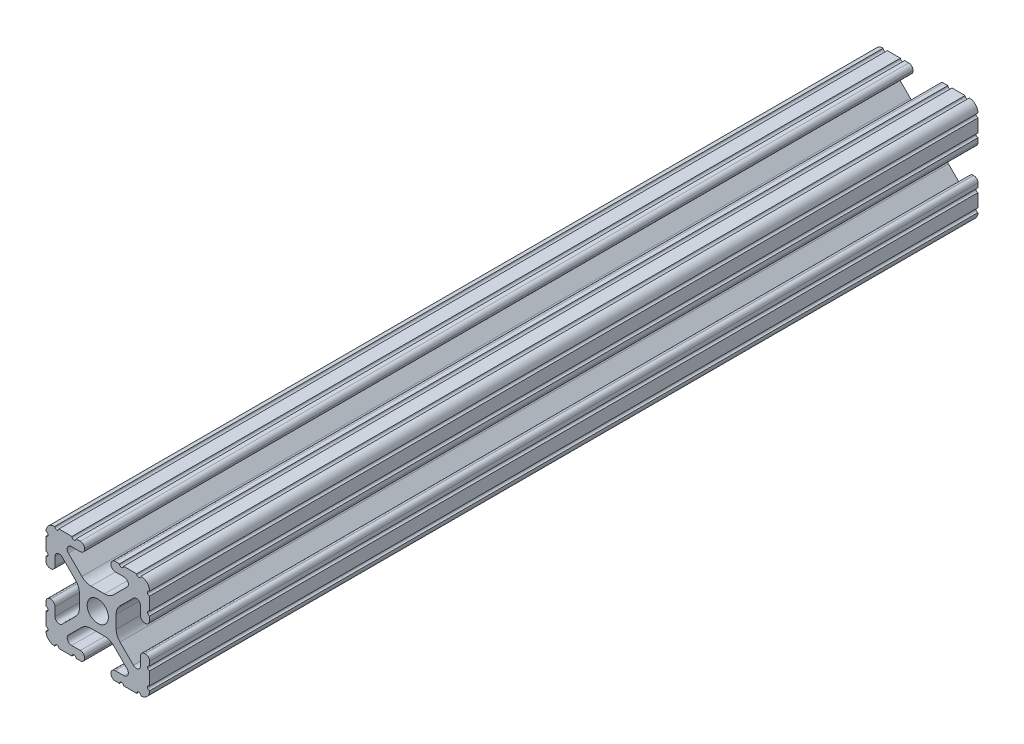
from build123d import *

# Parameters (mm, degrees)
SKETCH3_R           = 2.6035
BOSS_EXTRUDE1_DEPTH = 101.6


with BuildPart() as part:
    # Sketch3 → Boss-Extrude1 (new body, symmetric)
    with BuildSketch(Plane.XY):
        with BuildLine():
            Line((-7.179650497, -8.645192506), (-3.952270251, -5.423690499))
            ThreePointArc((-3.952270251, -5.423690499), (-2.922936451, -4.736929036), (-1.709253557, -4.4958))
            Line((-1.709253557, -4.4958), (1.709253557, -4.4958))
            ThreePointArc((1.709253557, -4.4958), (2.922936451, -4.736929036), (3.952270251, -5.423690499))
            Line((3.952270251, -5.423690499), (7.179650497, -8.645192506))
            ThreePointArc((7.179650497, -8.645192506), (7.41473083, -9.822813117), (6.416408329, -10.4902))
            Line((6.416408329, -10.4902), (4.287512407, -10.4902))
            ThreePointArc((4.287512407, -10.4902), (3.54574862, -10.79744862), (3.2385, -11.539212407))
            Line((3.2385, -11.539212407), (3.2385, -11.650987593))
            ThreePointArc((3.2385, -11.650987593), (3.54574862, -12.39275138), (4.287512407, -12.7))
            Line((4.287512407, -12.7), (5.317126718, -12.7))
            ThreePointArc((5.317126718, -12.7), (5.825126718, -12.192), (6.333126718, -12.7))
            Line((6.333126718, -12.7), (9.550443118, -12.7))
            ThreePointArc((9.550443118, -12.7), (10.058366869, -12.192000006), (10.566443095, -12.699847501))
            ThreePointArc((10.566443095, -12.699847501), (12.082537762, -12.08250727), (12.699846982, -10.566399977))
            ThreePointArc((12.699846982, -10.566399977), (12.192000006, -10.058323491), (12.7, -9.5504))
            Line((12.7, -9.5504), (12.7, -6.3330836))
            ThreePointArc((12.7, -6.3330836), (12.192, -5.8250836), (12.7, -5.3170836))
            Line((12.7, -5.3170836), (12.7, -4.287469289))
            ThreePointArc((12.7, -4.287469289), (12.39275138, -3.545705502), (11.650987593, -3.238456882))
            Line((11.650987593, -3.238456882), (11.539212407, -3.238456882))
            ThreePointArc((11.539212407, -3.238456882), (10.79744862, -3.545705502), (10.4902, -4.287469289))
            Line((10.4902, -4.287469289), (10.4902, -6.402089023))
            ThreePointArc((10.4902, -6.402089023), (9.856505071, -7.351067942), (8.737131347, -7.129408934))
            Line((8.737131347, -7.129408934), (5.441005833, -3.840816462))
            ThreePointArc((5.441005833, -3.840816462), (4.750877967, -2.809883091), (4.5085, -1.593185507))
            Line((4.5085, -1.593185507), (4.5085, 1.593185507))
            ThreePointArc((4.5085, 1.593185507), (4.750877967, 2.809883091), (5.441005833, 3.840816462))
            Line((5.441005833, 3.840816462), (8.737131347, 7.129408934))
            ThreePointArc((8.737131347, 7.129408934), (9.856505071, 7.351067942), (10.4902, 6.402089023))
            Line((10.4902, 6.402089023), (10.4902, 4.287469289))
            ThreePointArc((10.4902, 4.287469289), (10.79744862, 3.545705502), (11.539212407, 3.238456882))
            Line((11.539212407, 3.238456882), (11.650987593, 3.238456882))
            ThreePointArc((11.650987593, 3.238456882), (12.39275138, 3.545705502), (12.7, 4.287469289))
            Line((12.7, 4.287469289), (12.7, 5.3170836))
            ThreePointArc((12.7, 5.3170836), (12.192, 5.8250836), (12.7, 6.3330836))
            Line((12.7, 6.3330836), (12.7, 9.5504))
            ThreePointArc((12.7, 9.5504), (12.192000006, 10.058323491), (12.699846982, 10.566399977))
            ThreePointArc((12.699846982, 10.566399977), (12.082537762, 12.08250727), (10.566443095, 12.699847501))
            ThreePointArc((10.566443095, 12.699847501), (10.058366869, 12.192000006), (9.550443118, 12.7))
            Line((9.550443118, 12.7), (6.333126718, 12.7))
            ThreePointArc((6.333126718, 12.7), (5.825126718, 12.192), (5.317126718, 12.7))
            Line((5.317126718, 12.7), (4.287512407, 12.7))
            ThreePointArc((4.287512407, 12.7), (3.54574862, 12.39275138), (3.2385, 11.650987593))
            Line((3.2385, 11.650987593), (3.2385, 11.539212407))
            ThreePointArc((3.2385, 11.539212407), (3.54574862, 10.79744862), (4.287512407, 10.4902))
            Line((4.287512407, 10.4902), (6.476788598, 10.4902))
            ThreePointArc((6.476788598, 10.4902), (7.432222385, 9.85140422), (7.207036008, 8.724370562))
            Line((7.207036008, 8.724370562), (3.898272566, 5.423169045))
            ThreePointArc((3.898272566, 5.423169045), (2.869120213, 4.736787962), (1.655778399, 4.4958))
            Line((1.655778399, 4.4958), (-1.655778399, 4.4958))
            ThreePointArc((-1.655778399, 4.4958), (-2.869120213, 4.736787962), (-3.898272566, 5.423169045))
            Line((-3.898272566, 5.423169045), (-7.207036008, 8.724370562))
            ThreePointArc((-7.207036008, 8.724370562), (-7.432222385, 9.85140422), (-6.476788598, 10.4902))
            Line((-6.476788598, 10.4902), (-4.287512407, 10.4902))
            ThreePointArc((-4.287512407, 10.4902), (-3.54574862, 10.79744862), (-3.2385, 11.539212407))
            Line((-3.2385, 11.539212407), (-3.2385, 11.650987593))
            ThreePointArc((-3.2385, 11.650987593), (-3.54574862, 12.39275138), (-4.287512407, 12.7))
            Line((-4.287512407, 12.7), (-5.317126718, 12.7))
            ThreePointArc((-5.317126718, 12.7), (-5.825126718, 12.192), (-6.333126718, 12.7))
            Line((-6.333126718, 12.7), (-9.550443118, 12.7))
            ThreePointArc((-9.550443118, 12.7), (-10.058366869, 12.192000006), (-10.566443095, 12.699847501))
            ThreePointArc((-10.566443095, 12.699847501), (-12.082537762, 12.08250727), (-12.699846982, 10.566399977))
            ThreePointArc((-12.699846982, 10.566399977), (-12.192000006, 10.058323491), (-12.7, 9.5504))
            Line((-12.7, 9.5504), (-12.7, 6.3330836))
            ThreePointArc((-12.7, 6.3330836), (-12.192, 5.8250836), (-12.7, 5.3170836))
            Line((-12.7, 5.3170836), (-12.7, 4.287469289))
            ThreePointArc((-12.7, 4.287469289), (-12.39275138, 3.545705502), (-11.650987593, 3.238456882))
            Line((-11.650987593, 3.238456882), (-11.539212407, 3.238456882))
            ThreePointArc((-11.539212407, 3.238456882), (-10.79744862, 3.545705502), (-10.4902, 4.287469289))
            Line((-10.4902, 4.287469289), (-10.4902, 6.402089023))
            ThreePointArc((-10.4902, 6.402089023), (-9.856505071, 7.351067942), (-8.737131347, 7.129408934))
            Line((-8.737131347, 7.129408934), (-5.441005833, 3.840816462))
            ThreePointArc((-5.441005833, 3.840816462), (-4.750877967, 2.809883091), (-4.5085, 1.593185507))
            Line((-4.5085, 1.593185507), (-4.5085, -1.593185507))
            ThreePointArc((-4.5085, -1.593185507), (-4.750877967, -2.809883091), (-5.441005833, -3.840816462))
            Line((-5.441005833, -3.840816462), (-8.737131347, -7.129408934))
            ThreePointArc((-8.737131347, -7.129408934), (-9.856505071, -7.351067942), (-10.4902, -6.402089023))
            Line((-10.4902, -6.402089023), (-10.4902, -4.287469289))
            ThreePointArc((-10.4902, -4.287469289), (-10.79744862, -3.545705502), (-11.539212407, -3.238456882))
            Line((-11.539212407, -3.238456882), (-11.650987593, -3.238456882))
            ThreePointArc((-11.650987593, -3.238456882), (-12.39275138, -3.545705502), (-12.7, -4.287469289))
            Line((-12.7, -4.287469289), (-12.7, -5.3170836))
            ThreePointArc((-12.7, -5.3170836), (-12.192, -5.8250836), (-12.7, -6.3330836))
            Line((-12.7, -6.3330836), (-12.7, -9.5504))
            ThreePointArc((-12.7, -9.5504), (-12.192000006, -10.058323491), (-12.699846982, -10.566399977))
            ThreePointArc((-12.699846982, -10.566399977), (-12.082537762, -12.08250727), (-10.566443095, -12.699847501))
            ThreePointArc((-10.566443095, -12.699847501), (-10.058366869, -12.192000006), (-9.550443118, -12.7))
            Line((-9.550443118, -12.7), (-6.333126718, -12.7))
            ThreePointArc((-6.333126718, -12.7), (-5.825126718, -12.192), (-5.317126718, -12.7))
            Line((-5.317126718, -12.7), (-4.287512407, -12.7))
            ThreePointArc((-4.287512407, -12.7), (-3.54574862, -12.39275138), (-3.2385, -11.650987593))
            Line((-3.2385, -11.650987593), (-3.2385, -11.539212407))
            ThreePointArc((-3.2385, -11.539212407), (-3.54574862, -10.79744862), (-4.287512407, -10.4902))
            Line((-4.287512407, -10.4902), (-6.416408329, -10.4902))
            ThreePointArc((-6.416408329, -10.4902), (-7.41473083, -9.822813117), (-7.179650497, -8.645192506))
        make_face()
        Circle(SKETCH3_R, mode=Mode.SUBTRACT)
    extrude(amount=BOSS_EXTRUDE1_DEPTH, both=True)


solid = part.part
